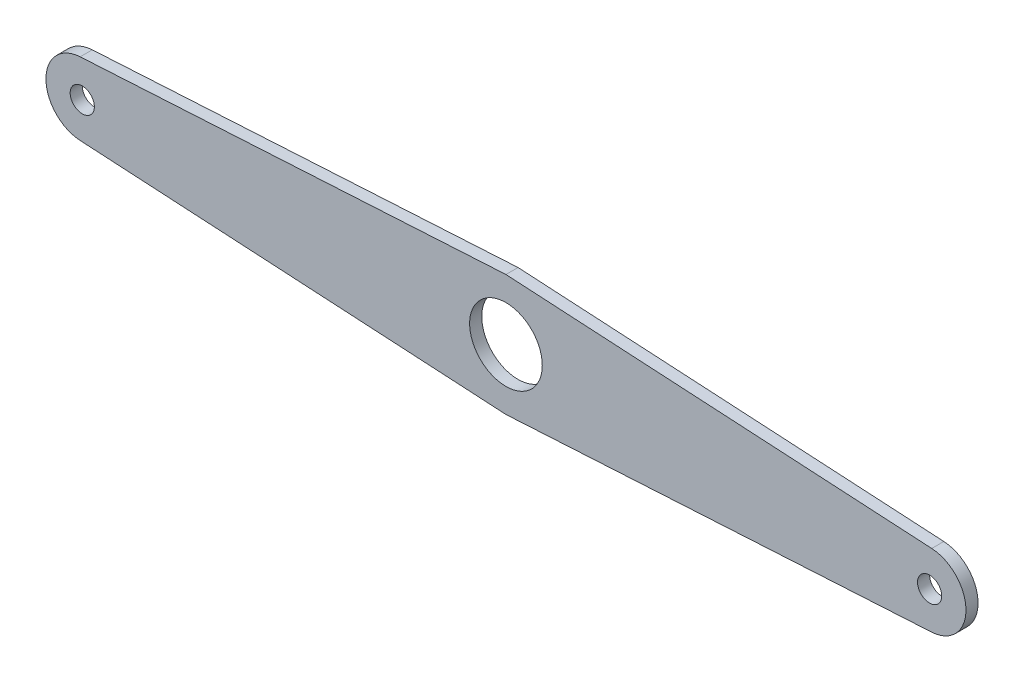
from build123d import *

# Parameters (mm, degrees)
SKETCH1_R           = 5
SKETCH1_R_2         = 15
BOSS_EXTRUDE1_DEPTH = 5


with BuildPart() as part:
    # Sketch1 → Boss-Extrude1 (new body)
    with BuildSketch(Plane.XY):
        with BuildLine():
            Line((0, 25.040916558), (-175.857142857, 14.97549018))
            ThreePointArc((-175.857142857, 14.97549018), (-190, 0), (-175.857142857, -14.97549018))
            Line((-175.857142857, -14.97549018), (0, -25.040916558))
            Line((0, -25.040916558), (175.857142857, -14.97549018))
            ThreePointArc((175.857142857, -14.97549018), (190, 0), (175.857142857, 14.97549018))
            Line((175.857142857, 14.97549018), (0, 25.040916558))
        make_face()
        with Locations((-175, 0)):
            Circle(SKETCH1_R, mode=Mode.SUBTRACT)
        Circle(SKETCH1_R_2, mode=Mode.SUBTRACT)
        with Locations((175, 0)):
            Circle(SKETCH1_R, mode=Mode.SUBTRACT)
    extrude(amount=BOSS_EXTRUDE1_DEPTH)


solid = part.part
